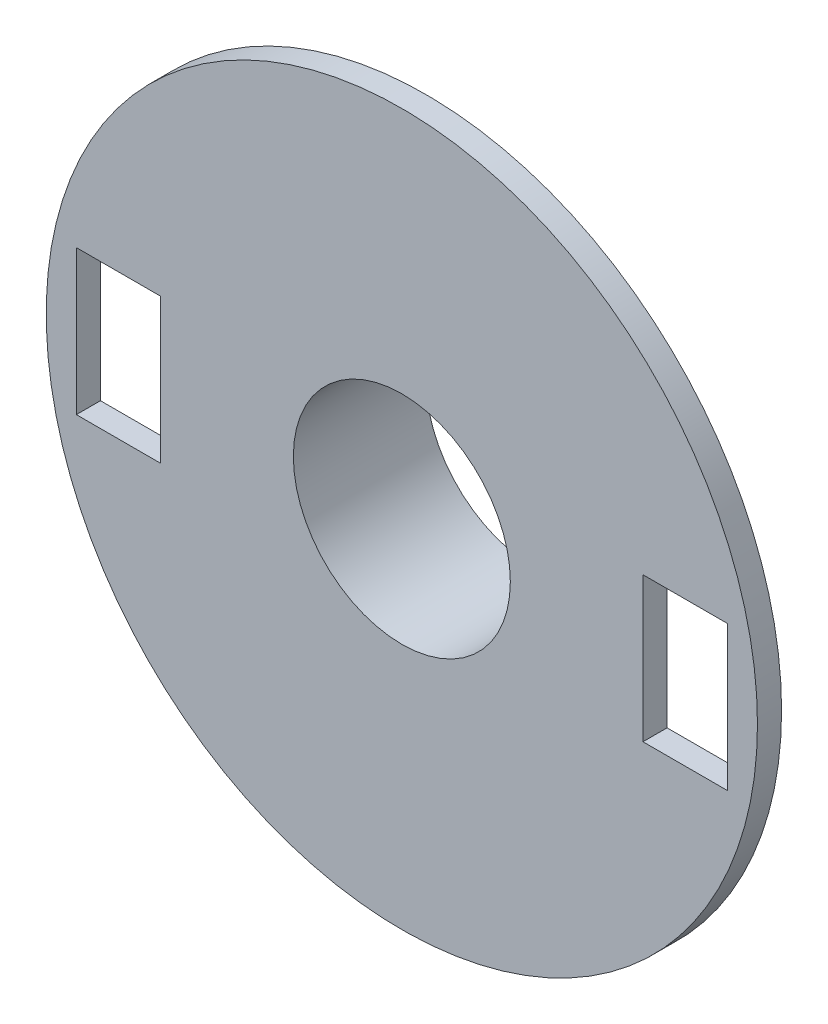
from build123d import *

# Parameters (mm, degrees)
SKETCH1_R           = 14.75
BOSS_EXTRUDE1_DEPTH = 1
SKETCH2_R           = 5
BOSS_EXTRUDE2_DEPTH = 4.5
SKETCH3_R           = 4.5
SKETCH3_W           = 3.5
SKETCH3_H           = 6
CUT_EXTRUDE1_DEPTH  = 6.5


with BuildPart() as part:
    # Sketch1 → Boss-Extrude1 (new body)
    with BuildSketch(Plane.XY):
        Circle(SKETCH1_R)
    extrude(amount=BOSS_EXTRUDE1_DEPTH)

    # Sketch2 → Boss-Extrude2 (add)
    with BuildSketch(Plane(origin=(0, 0, 0), x_dir=(-1, 0, 0), z_dir=(0, 0, -1))):
        Circle(SKETCH2_R)
    extrude(amount=BOSS_EXTRUDE2_DEPTH)

    # Sketch3 → Cut-Extrude1 (cut, through all)
    with BuildSketch(Plane(origin=(0, 0, -4.5), x_dir=(-1, 0, 0), z_dir=(0, 0, -1))):
        Circle(SKETCH3_R)
        with Locations((-11.75, 0)):
            Rectangle(SKETCH3_W, SKETCH3_H)
        with Locations((11.75, 0)):
            Rectangle(SKETCH3_W, SKETCH3_H)
    extrude(amount=-CUT_EXTRUDE1_DEPTH, mode=Mode.SUBTRACT)


solid = part.part
